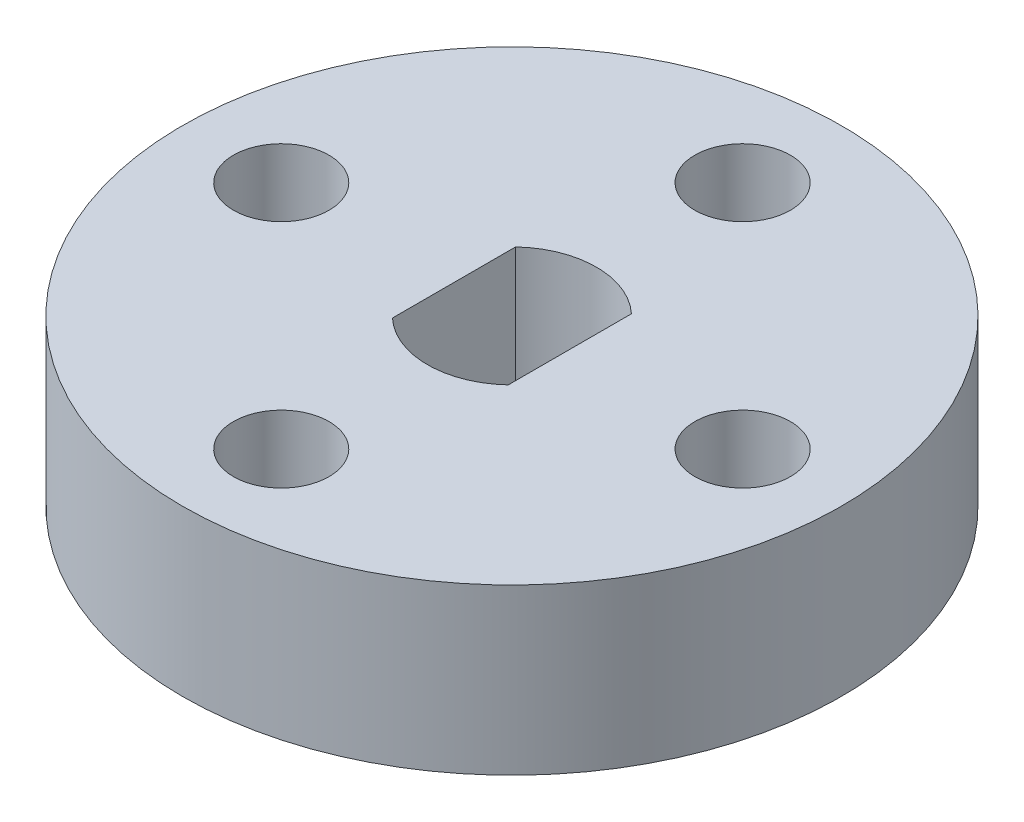
from build123d import *

# Parameters (mm, degrees)
SKETCH_1_R      = 10
SKETCH_1_R_2    = 1.45
EXTRUDE_1_DEPTH = 2.5


with BuildPart() as part:
    # 草图1 → 凸台-拉伸1 (new body, symmetric)
    with BuildSketch(Plane(origin=(0, 0, 0), x_dir=(1, 0, 0), z_dir=(0, 1, 0))):
        Circle(SKETCH_1_R)
        with Locations((7, 0)):
            Circle(SKETCH_1_R_2, mode=Mode.SUBTRACT)
        with Locations((0, 7)):
            Circle(SKETCH_1_R_2, mode=Mode.SUBTRACT)
        with Locations((-7, 0)):
            Circle(SKETCH_1_R_2, mode=Mode.SUBTRACT)
        with Locations((0, -7)):
            Circle(SKETCH_1_R_2, mode=Mode.SUBTRACT)
        with BuildLine():
            Line((1.7575, 0), (1.7575, 1.868266242))
            ThreePointArc((1.7575, 1.868266242), (0, 2.565), (-1.7575, 1.868266242))
            Line((-1.7575, 1.868266242), (-1.7575, 0))
            Line((-1.7575, 0), (-1.7575, -1.868266242))
            ThreePointArc((-1.7575, -1.868266242), (0, -2.565), (1.7575, -1.868266242))
            Line((1.7575, -1.868266242), (1.7575, 0))
        make_face(mode=Mode.SUBTRACT)
    extrude(amount=EXTRUDE_1_DEPTH, both=True)


solid = part.part
